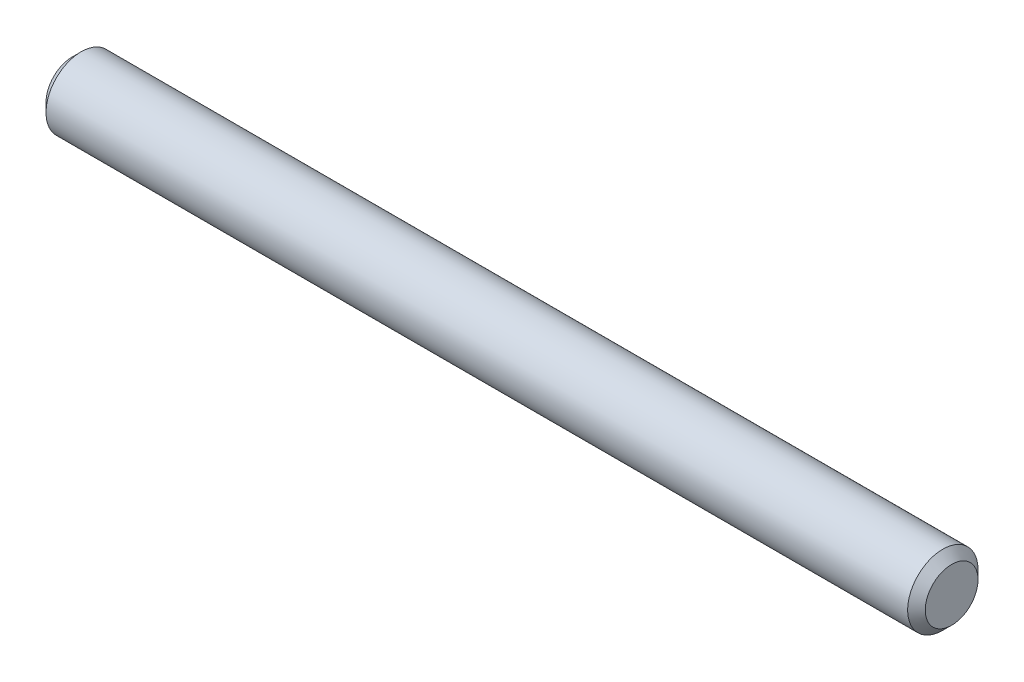
from build123d import *

# Parameters (mm, degrees)
SKETCH1_R           = 2
BOSS_EXTRUDE1_DEPTH = 25
CHAMFER1_SIZE       = 0.5


with BuildPart() as part:
    # Sketch1 → Boss-Extrude1 (new, symmetric)
    with BuildSketch(Plane(origin=(0, 0, 0), x_dir=(0, 0, -1), z_dir=(1, 0, 0))):
        Circle(SKETCH1_R)
    extrude(amount=BOSS_EXTRUDE1_DEPTH, both=True)

    # Chamfer1
    chamfer1_edges = [part.edges().sort_by_distance(p)[0] for p in [
        (-25, 0, 2),
        (25, 0, 2),
    ]]
    chamfer(chamfer1_edges, length=CHAMFER1_SIZE)


solid = part.part
